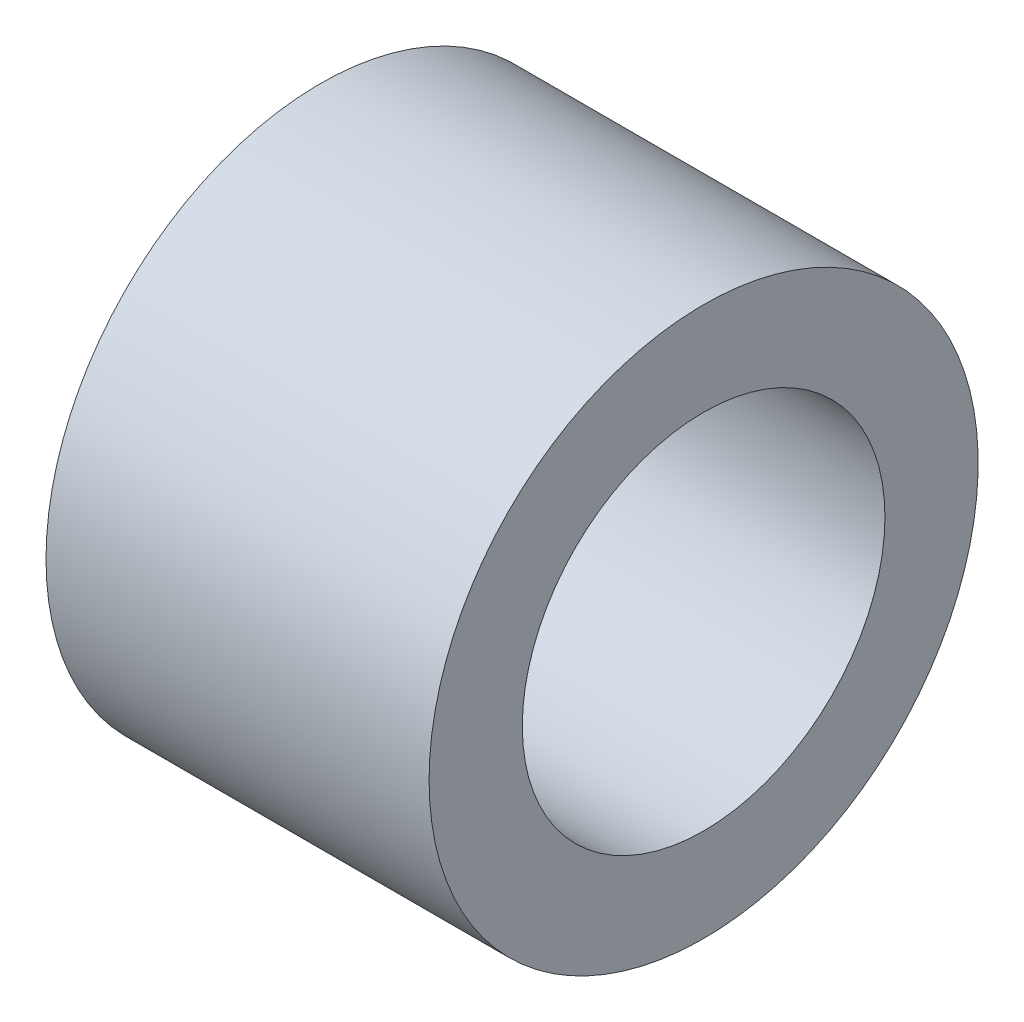
from build123d import *

# Parameters (mm, degrees)
ESQUISSE1_W = 15
ESQUISSE1_H = 3.65


with BuildPart() as part:
    # Esquisse1 → Révolution1 (revolve)
    with BuildSketch(Plane.XY, mode=Mode.PRIVATE) as r_volution1_sk:
        with Locations((-6.614021, 8.925)):
            Rectangle(ESQUISSE1_W, ESQUISSE1_H)
    revolve(r_volution1_sk.sketch.rotate(Axis((-32.836701031, 0, 0), (1, 0, 0)), 90), axis=Axis((-32.836701031, 0, 0), (1, 0, 0)))  # turned: the seam where the file's is


solid = part.part
